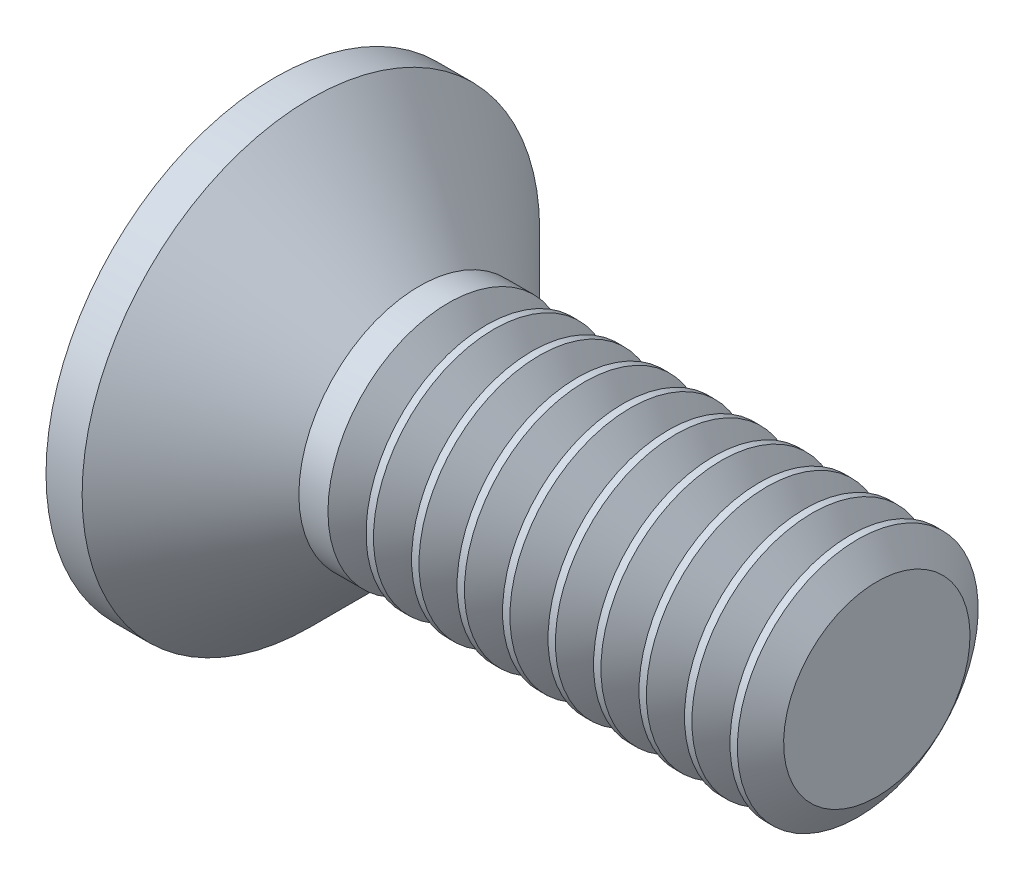
from build123d import *

# Parameters (mm, degrees)
SKETCH3_W         = 0.53
SKETCH3_H         = 2.14
SKETCH4_W         = 0.265
SKETCH4_H         = 0.265
CIRPATTERN1_COUNT = 2
CIRPATTERN1_ANGLE = 90
THDSCHPAT_COUNT   = 10
THDSCHPAT_PITCH   = 0.377777778


with BuildPart() as part:
    # BodySke → Base-Revolve (revolve)
    with BuildSketch(Plane.XY):
        Polygon((0, 0), (0, 1.9), (0.3, 1.9), (1.2, 1), (5, 1), (5, 0), align=None)
    revolve(axis=Axis((-6.35, 0, 0), (1, 0, 0)))

    # Sketch3 → Cross section 0
    with BuildSketch(Plane.ZY):
        Rectangle(SKETCH3_W, SKETCH3_H)
    # Sketch4 → Cross section 1
    with BuildSketch(Plane.ZY.offset(-1.54)):
        Rectangle(SKETCH4_W, SKETCH4_H)
    cross = loft(mode=Mode.SUBTRACT)

    # CirPattern1: Cross ×2 about axis
    cirpattern1_axis = Axis((0, 0, 0), (1, 0, 0))
    for i in range(1, CIRPATTERN1_COUNT):
        add(cross.rotate(cirpattern1_axis, i * CIRPATTERN1_ANGLE / (CIRPATTERN1_COUNT - 1)), mode=Mode.SUBTRACT)

    # ThdSchSke → ThreadSchematic (revolve, cut)
    with BuildSketch(Plane.XY):
        Polygon((1.600001, -0.774), (1.441754096, -1), (1.441754096, -1.25), (1.758247904, -1.25), (1.758247904, -1), align=None)
    threadschematic = revolve(axis=Axis((-3.175, 0, 0), (1, 0, 0)), mode=Mode.SUBTRACT)

    # ThdSchPat: ThreadSchematic ×10
    with Locations(*[(i * THDSCHPAT_PITCH, 0, 0) for i in range(1, THDSCHPAT_COUNT)]):
        add(threadschematic, mode=Mode.SUBTRACT)


solid = part.part
